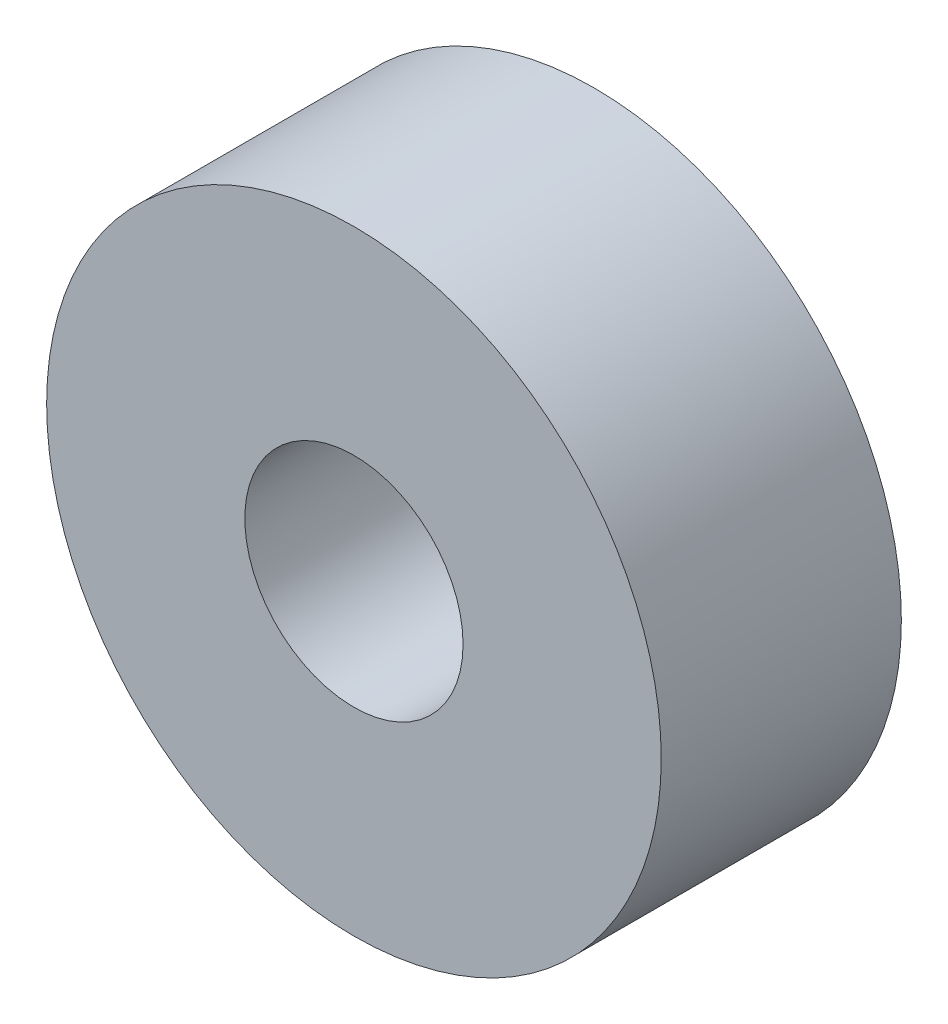
from build123d import *

# Parameters (mm, degrees)
SKETCH1_R           = 11.176
SKETCH1_R_2         = 3.96875
BOSS_EXTRUDE1_DEPTH = 8.73252


with BuildPart() as part:
    # Sketch1 → Boss-Extrude1 (new body)
    with BuildSketch(Plane.XY):
        Circle(SKETCH1_R)
        Circle(SKETCH1_R_2, mode=Mode.SUBTRACT)
    extrude(amount=BOSS_EXTRUDE1_DEPTH)


solid = part.part
